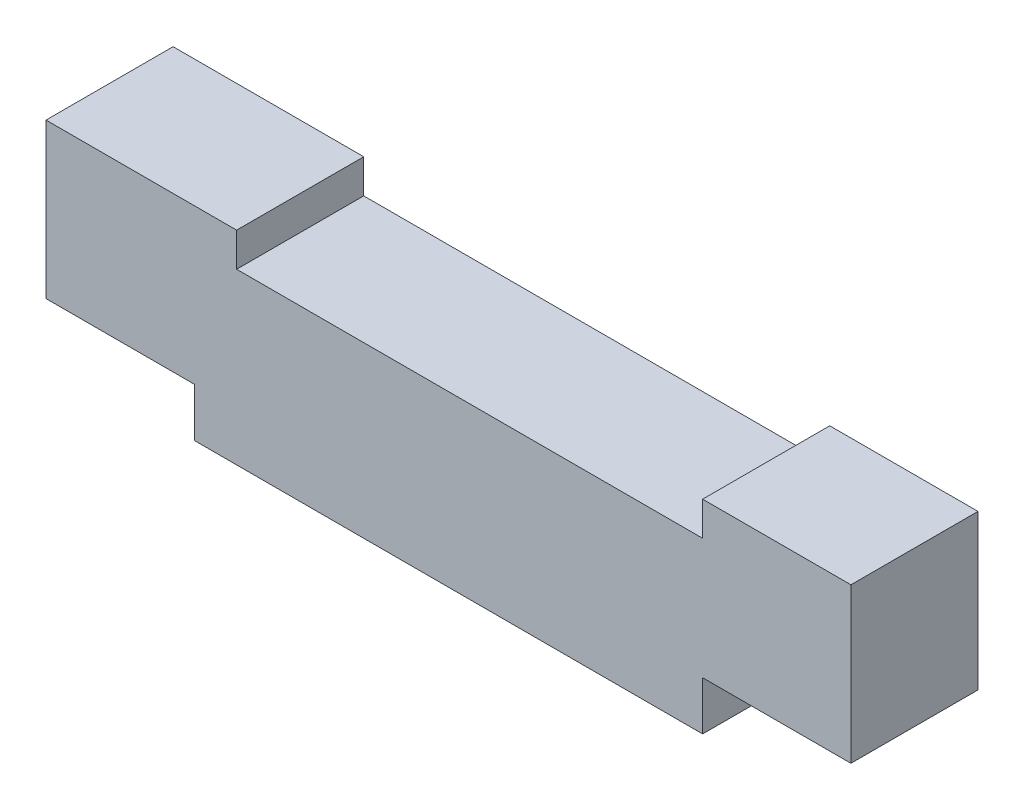
from build123d import *

# Parameters (mm, degrees)
EXTRUSION1_DEPTH = 30


with BuildPart() as part:
    # Esquisse1 → Extrusion1 (new body)
    with BuildSketch(Plane.XY):
        Polygon((90, 0), (-30, 0), (-30, 11.5), (-65, 11.5), (-65, 48), (-20, 48), (-20, 40), (90, 40), (90, 48), (125, 48), (125, 11.5), (90, 11.5), align=None)
    extrude(amount=EXTRUSION1_DEPTH)


solid = part.part
